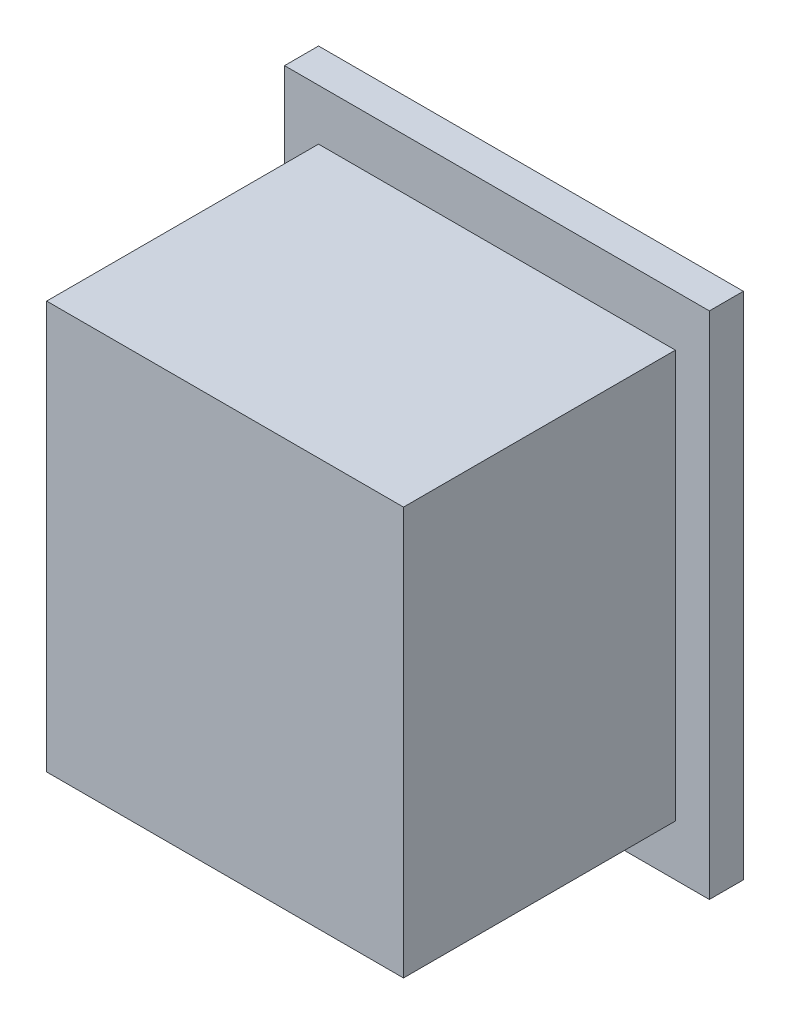
from build123d import *

# Parameters (mm, degrees)
SKETCH1_W           = 21
SKETCH1_H           = 24
BOSS_EXTRUDE1_DEPTH = 16
SKETCH2_W           = 25
SKETCH2_H           = 30
BOSS_EXTRUDE2_DEPTH = 2


with BuildPart() as part:
    # Sketch1 → Boss-Extrude1 (new body)
    with BuildSketch(Plane.XY):
        with Locations((-2.082524272, 1.165048544)):
            Rectangle(SKETCH1_W, SKETCH1_H)
    extrude(amount=BOSS_EXTRUDE1_DEPTH)

    # Sketch2 → Boss-Extrude2 (add)
    with BuildSketch(Plane(origin=(0, 0, 0), x_dir=(-1, 0, 0), z_dir=(0, 0, -1))):
        with Locations((2.082524272, 1.165048544)):
            Rectangle(SKETCH2_W, SKETCH2_H)
    extrude(amount=BOSS_EXTRUDE2_DEPTH)


solid = part.part
